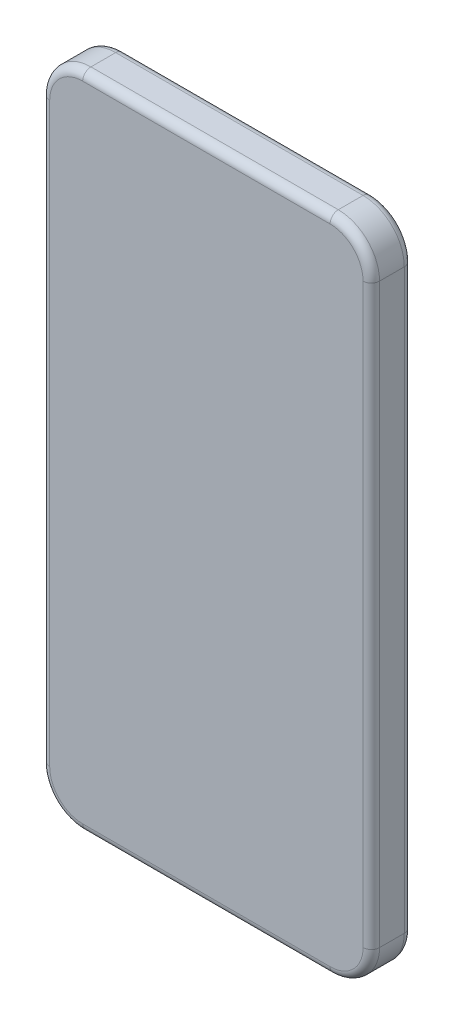
from build123d import *

# Parameters (mm, degrees)
BOSS_EXTRUDE1_DEPTH = 10
FILLET1_R           = 2


with BuildPart() as part:
    # Sketch1 → Boss-Extrude1 (new body)
    with BuildSketch(Plane.XY):
        with BuildLine():
            Line((30, 80), (-30, 80))
            ThreePointArc((-30, 80), (-37.071067812, 77.071067812), (-40, 70))
            Line((-40, 70), (-40, -70))
            ThreePointArc((-40, -70), (-37.071067812, -77.071067812), (-30, -80))
            Line((-30, -80), (30, -80))
            ThreePointArc((30, -80), (37.071067812, -77.071067812), (40, -70))
            Line((40, -70), (40, 70))
            ThreePointArc((40, 70), (37.071067812, 77.071067812), (30, 80))
        make_face()
    extrude(amount=BOSS_EXTRUDE1_DEPTH)

    # Fillet1
    fillet1_edges = [part.edges().sort_by_distance(p)[0] for p in [
        (37.071067812, 77.071067812, 10),
        (40, 0, 0),
        (37.071067812, -77.071067812, 0),
        (0, 80, 10),
        (-37.071067812, 77.071067812, 10),
        (-40, 0, 10),
        (-37.071067812, -77.071067812, 10),
        (0, -80, 10),
        (37.071067812, -77.071067812, 10),
        (40, 0, 10),
        (0, -80, 0),
        (-37.071067812, -77.071067812, 0),
        (-40, 0, 0),
        (-37.071067812, 77.071067812, 0),
        (0, 80, 0),
        (37.071067812, 77.071067812, 0),
    ]]
    fillet(fillet1_edges, radius=FILLET1_R)


solid = part.part
